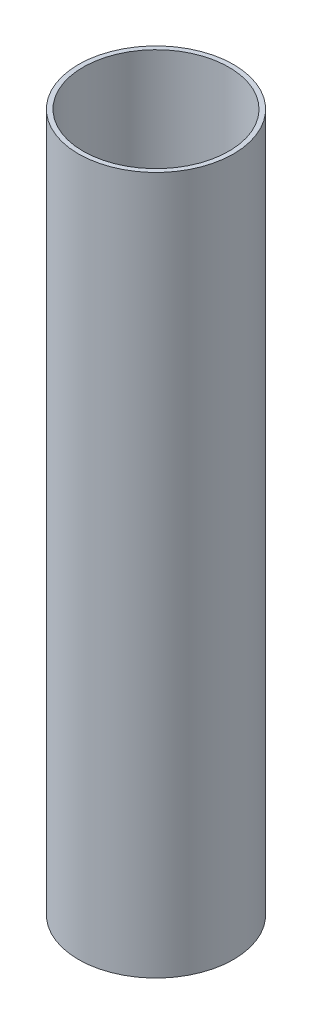
from build123d import *

# Parameters (mm, degrees)
SKETCH1_R           = 6.35
SKETCH1_R_2         = 5.969
BOSS_EXTRUDE1_DEPTH = 57.15


with BuildPart() as part:
    # Sketch1 → Boss-Extrude1 (new body)
    with BuildSketch(Plane(origin=(0, 0, 0), x_dir=(1, 0, 0), z_dir=(0, 1, 0))):
        Circle(SKETCH1_R)
        Circle(SKETCH1_R_2, mode=Mode.SUBTRACT)
    extrude(amount=BOSS_EXTRUDE1_DEPTH)


solid = part.part
